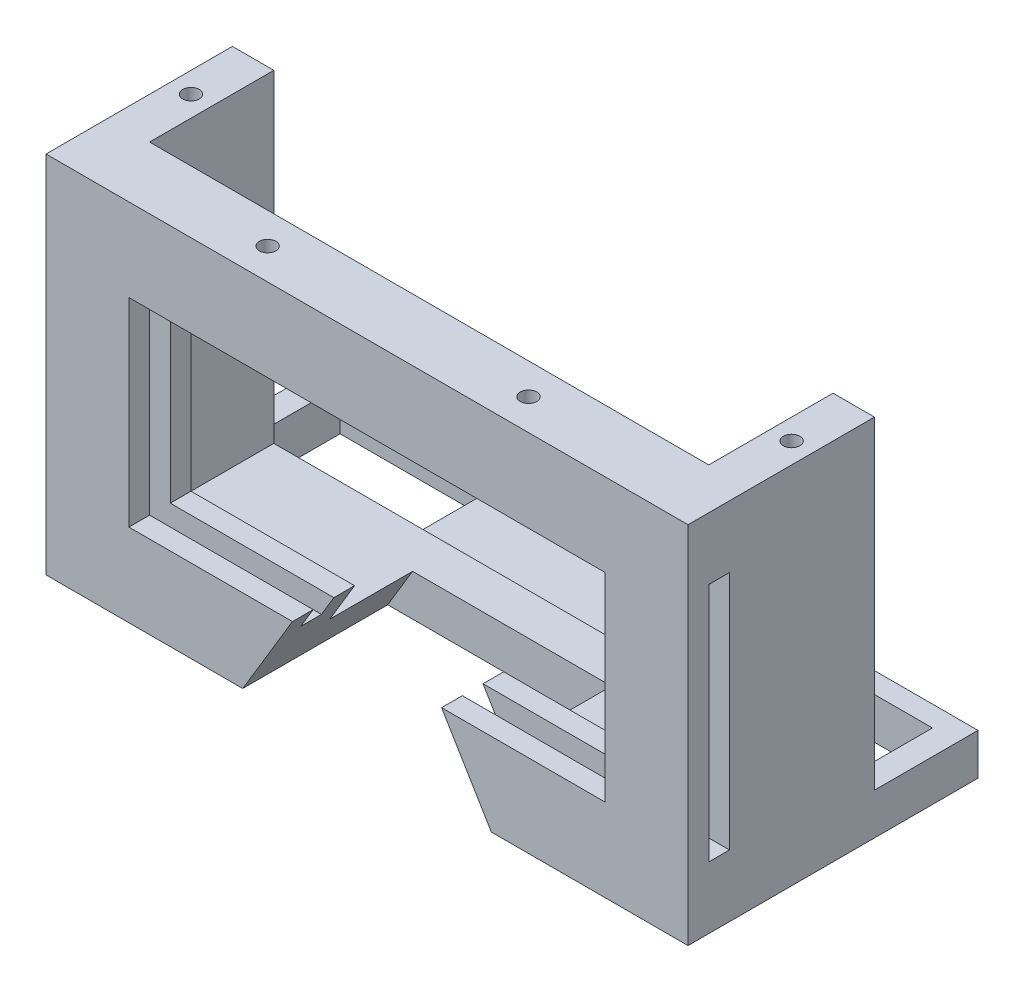
from build123d import *

# Parameters (mm, degrees)
SKETCH1_W           = 155
SKETCH1_H           = 55
BOSS_EXTRUDE1_DEPTH = 10
SKETCH2_W           = 143
SKETCH2_H           = 20
CUT_EXTRUDE1_DEPTH  = 5
SKETCH3_W           = 10
SKETCH3_H           = 30
BOSS_EXTRUDE2_DEPTH = 78
SKETCH4_W           = 35
SKETCH4_H           = 20
SKETCH4_W_2         = 50
CUT_EXTRUDE2_DEPTH  = 78
SKETCH5_W           = 155
SKETCH5_H           = 88
BOSS_EXTRUDE3_DEPTH = 15
SKETCH6_W           = 115
SKETCH6_H           = 48
CUT_EXTRUDE3_DEPTH  = 20
SKETCH7_W           = 5
SKETCH7_H           = 58
CUT_EXTRUDE4_DEPTH  = 200
CUT_EXTRUDE5_DEPTH  = 35
SKETCH9_R           = 2
CUT_EXTRUDE6_DEPTH  = 10
SKETCH10_R          = 2
CUT_EXTRUDE7_DEPTH  = 20


with BuildPart() as part:
    # Sketch1 → Boss-Extrude1 (new body)
    with BuildSketch(Plane(origin=(0, 0, 0), x_dir=(1, 0, 0), z_dir=(0, 1, 0))):
        with Locations((77.5, -27.5)):
            Rectangle(SKETCH1_W, SKETCH1_H)
    extrude(amount=BOSS_EXTRUDE1_DEPTH)

    # Sketch2 → Cut-Extrude1 (cut)
    with BuildSketch(Plane(origin=(0, 10, 0), x_dir=(1, 0, 0), z_dir=(0, 1, 0))):
        with Locations((77.5, -15)):
            Rectangle(SKETCH2_W, SKETCH2_H)
    extrude(amount=-CUT_EXTRUDE1_DEPTH, mode=Mode.SUBTRACT)

    # Sketch3 → Boss-Extrude2 (add)
    with BuildSketch(Plane(origin=(0, 10, 0), x_dir=(1, 0, 0), z_dir=(0, 1, 0))):
        with Locations((5, -40)):
            Rectangle(SKETCH3_W, SKETCH3_H)
        with Locations((150, -40)):
            Rectangle(SKETCH3_W, SKETCH3_H)
    extrude(amount=BOSS_EXTRUDE2_DEPTH)

    # Sketch4 → Cut-Extrude2 (cut)
    with BuildSketch(Plane(origin=(0, 5, 0), x_dir=(1, 0, 0), z_dir=(0, 1, 0))):
        with Locations((23.5, -15)):
            Rectangle(SKETCH4_W, SKETCH4_H)
        with Locations((124, -15)):
            Rectangle(SKETCH4_W_2, SKETCH4_H)
    extrude(amount=-CUT_EXTRUDE2_DEPTH, mode=Mode.SUBTRACT)

    # Sketch5 → Boss-Extrude3 (add)
    with BuildSketch(Plane.XY.offset(55)):
        with Locations((77.5, 44)):
            Rectangle(SKETCH5_W, SKETCH5_H)
    extrude(amount=BOSS_EXTRUDE3_DEPTH)

    # Sketch6 → Cut-Extrude3 (cut)
    with BuildSketch(Plane.XY.offset(70)):
        with Locations((77.5, 44)):
            Rectangle(SKETCH6_W, SKETCH6_H)
    extrude(amount=-CUT_EXTRUDE3_DEPTH, mode=Mode.SUBTRACT)

    # Sketch7 → Cut-Extrude4 (cut)
    with BuildSketch(Plane(origin=(155, 0, 0), x_dir=(0, 0, -1), z_dir=(1, 0, 0))):
        with Locations((-62.5, 44)):
            Rectangle(SKETCH7_W, SKETCH7_H)
    extrude(amount=-CUT_EXTRUDE4_DEPTH, mode=Mode.SUBTRACT)

    # Sketch8 → Cut-Extrude5 (cut)
    with BuildSketch(Plane.XY.offset(70)):
        Polygon((47.5, 0), (107.5, 0), (77.5, 50), align=None)
    extrude(amount=-CUT_EXTRUDE5_DEPTH, mode=Mode.SUBTRACT)

    # Sketch9 → Cut-Extrude6 (cut)
    with BuildSketch(Plane(origin=(0, 88, 0), x_dir=(1, 0, 0), z_dir=(0, 1, 0))):
        with Locations((150, -40)):
            Circle(SKETCH9_R)
        with Locations((5, -40)):
            Circle(SKETCH9_R)
    extrude(amount=-CUT_EXTRUDE6_DEPTH, mode=Mode.SUBTRACT)

    # Sketch10 → Cut-Extrude7 (cut)
    with BuildSketch(Plane(origin=(0, 88, 0), x_dir=(1, 0, 0), z_dir=(0, 1, 0))):
        with Locations((109, -62.5)):
            Circle(SKETCH10_R)
        with Locations((46, -62.5)):
            Circle(SKETCH10_R)
    extrude(amount=-CUT_EXTRUDE7_DEPTH, mode=Mode.SUBTRACT)


solid = part.part
